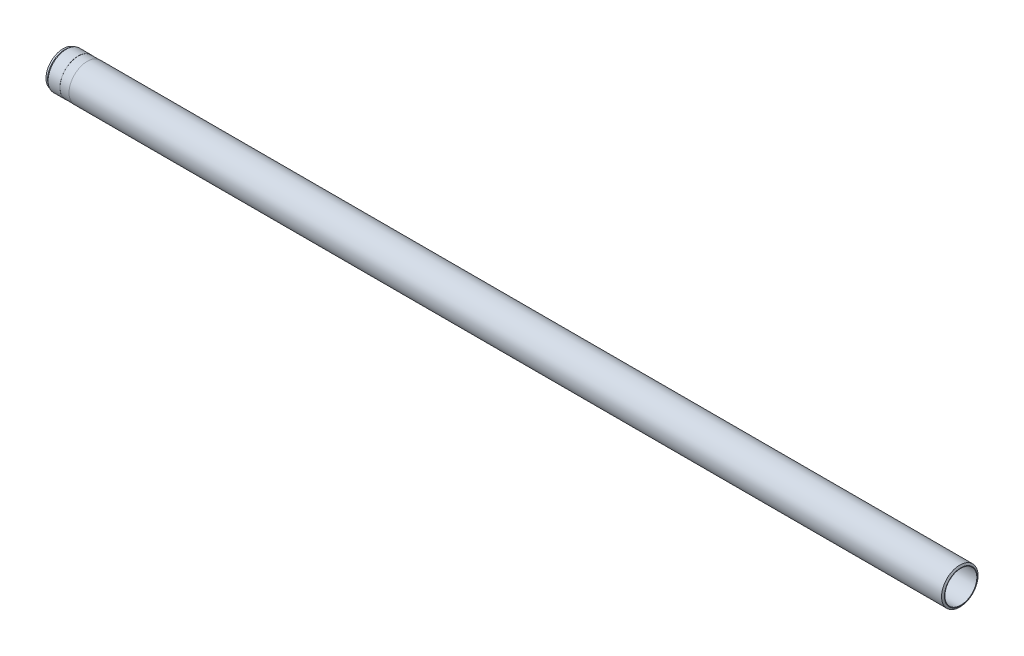
from build123d import *


with BuildPart() as part:
    # Sketch1 → Base-Revolve (revolve)
    with BuildSketch(Plane.XY):
        Polygon((0, 35), (0, 36), (-2.309401077, 40), (-1915, 40), (-1915, 39.75), (-1935, 39.75), (-1935, 40), (-1960.929629983, 40), (-1964.5, 37.5), (-1968, 37.5), (-1968, 35.727350269), (-1967, 35.15), (-1953, 35.15), (-1952.740192379, 35), align=None)
    revolve(axis=Axis((-122.784188742, 0, 0), (1, 0, 0)))


solid = part.part
